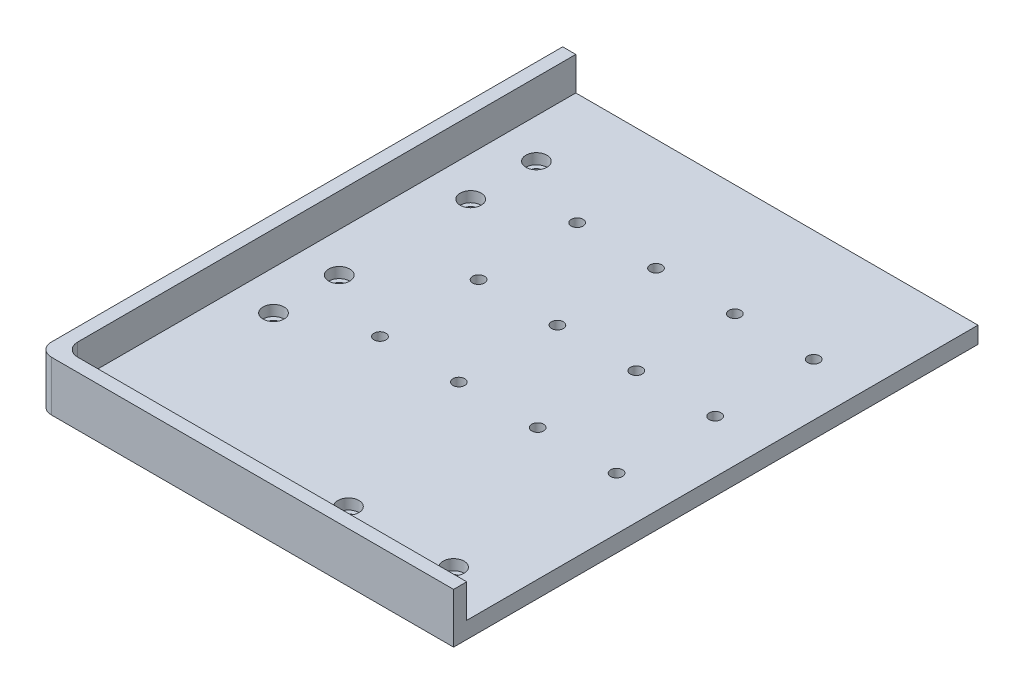
from build123d import *

# Parameters (mm, degrees)
SKETCH1_W                      = 158
SKETCH1_H                      = 199.5
BOSS_EXTRUDE1_DEPTH            = 6.35
BOSS_EXTRUDE2_DEPTH            = 12.7
CBORE_FOR_M4_SHCS1_D           = 4.5
CBORE_FOR_M4_SHCS1_DEPTH       = 6.35
CBORE_FOR_M4_SHCS1_CBORE_D     = 8
CBORE_FOR_M4_SHCS1_CBORE_DEPTH = 4
M4_CLEARANCE_HOLE2_D           = 4.5
M4_CLEARANCE_HOLE2_DEPTH       = 6.35
LPATTERN1_COUNT                = 4
LPATTERN1_PITCH                = 30
LPATTERN1_COUNT_DIR2           = 3
LPATTERN1_PITCH_DIR2           = 37.5
FILLET2_R                      = 5


with BuildPart() as part:
    # Sketch1 → Boss-Extrude1 (new body)
    with BuildSketch(Plane(origin=(0, 0, 0), x_dir=(1, 0, 0), z_dir=(0, 1, 0))):
        with Locations((79, -99.75)):
            Rectangle(SKETCH1_W, SKETCH1_H)
    extrude(amount=BOSS_EXTRUDE1_DEPTH)

    # Sketch3 → Boss-Extrude2 (add)
    with BuildSketch(Plane(origin=(0, 6.35, 0), x_dir=(1, 0, 0), z_dir=(0, 1, 0))):
        Polygon((0, 0), (0, -199.5), (158, -199.5), (158, -194.5), (5, -194.5), (5, 0), align=None)
    extrude(amount=BOSS_EXTRUDE2_DEPTH)

    # CBORE for M4 SHCS1
    with Locations(Plane(origin=(0, 6.35, 0), x_dir=(1, 0, 0), z_dir=(0, 1, 0))):
        with Locations((20, -55), (98, -179.5), (138, -179.5), (20, -130), (20, -105), (20, -30)):
            CounterBoreHole(CBORE_FOR_M4_SHCS1_D / 2, CBORE_FOR_M4_SHCS1_CBORE_D / 2, CBORE_FOR_M4_SHCS1_CBORE_DEPTH, depth=CBORE_FOR_M4_SHCS1_DEPTH)

    # M4 Clearance Hole2
    with Locations(Plane(origin=(0, 6.35, 0), x_dir=(1, 0, 0), z_dir=(0, 1, 0))):
        with Locations((138, -117.5)):
            m4_clearance_hole2 = Hole(M4_CLEARANCE_HOLE2_D / 2, depth=M4_CLEARANCE_HOLE2_DEPTH)

    # LPattern1: M4 Clearance Hole2 4 × 3
    with Locations(*[(-i * LPATTERN1_PITCH, 0, -j * LPATTERN1_PITCH_DIR2) for i in range(LPATTERN1_COUNT) for j in range(LPATTERN1_COUNT_DIR2) if (i, j) != (0, 0)]):
        add(m4_clearance_hole2, mode=Mode.SUBTRACT)

    # Fillet2
    fillet2_edges = [part.edges().sort_by_distance(p)[0] for p in [
        (5, 12.7, 194.5),
        (0, 9.525, 199.5),
    ]]
    fillet(fillet2_edges, radius=FILLET2_R)


solid = part.part
